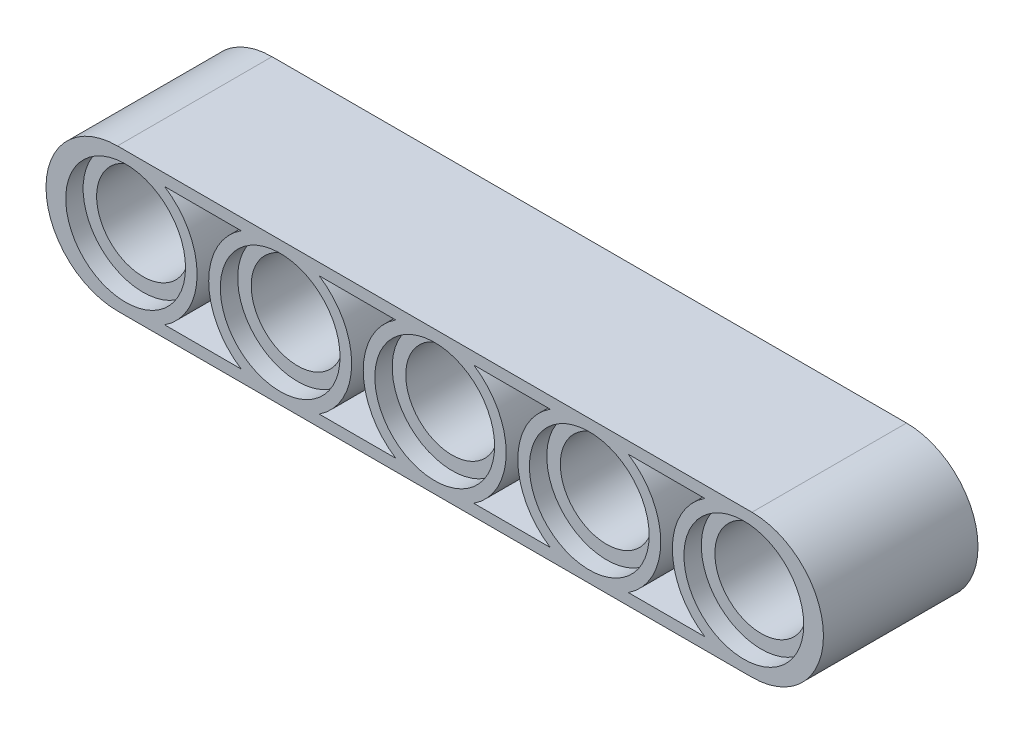
from build123d import *

# Parameters (mm, degrees)
OUTER_SHAPE_DEPTH  = 4
MIDDLE_WALL_DEPTH  = 0.1
HOLES_R            = 3.1
OUTER_HOLE_DEPTH   = 3.9
SKETCH3_R          = 3.1
SKETCH3_R_2        = 2.4
INNER_HOLE_DEPTH   = 3.1
SKETCH4_R          = 2.4
THROUGH_HOLE_DEPTH = 5


with BuildPart() as part:
    # Sketch1 → Outer Shape (new body)
    with BuildSketch(Plane.XY):
        with BuildLine():
            Line((-16.421445021, 3.7), (16.421445021, 3.7))
            ThreePointArc((16.421445021, 3.7), (20.121445021, 0), (16.421445021, -3.7))
            Line((16.421445021, -3.7), (-16.421445021, -3.7))
            ThreePointArc((-16.421445021, -3.7), (-20.121445021, 0), (-16.421445021, 3.7))
        make_face()
        with BuildLine():
            Line((-16, 3.1), (16, 3.1))
            ThreePointArc((16, 3.1), (19.1, 0), (16, -3.1))
            Line((16, -3.1), (-16, -3.1))
            ThreePointArc((-16, -3.1), (-19.1, 0), (-16, 3.1))
        make_face(mode=Mode.SUBTRACT)
    extrude(amount=OUTER_SHAPE_DEPTH)



with BuildPart() as body_2:
    # Sketch2 → Middle wall (new body)
    with BuildSketch(Plane.XY):
        with BuildLine():
            Line((-15.918927506, 3.189649288), (15.918927506, 3.189649288))
            ThreePointArc((15.918927506, 3.189649288), (19.108576794, 0), (15.918927506, -3.189649288))
            Line((15.918927506, -3.189649288), (-15.918927506, -3.189649288))
            ThreePointArc((-15.918927506, -3.189649288), (-19.108576794, 0), (-15.918927506, 3.189649288))
        make_face()
    extrude(amount=MIDDLE_WALL_DEPTH)


with BuildPart() as part_1:
    add(part.part)

    add(body_2.part)  # Outer Hole merges body 2
    # Holes → Outer Hole (add)
    with BuildSketch(Plane.XY.offset(0.1)):
        with BuildLine():
            Line((-6.12486336, 3.189649288), (-9.87513664, 3.189649288))
            ThreePointArc((-9.87513664, 3.189649288), (-11.7, 0), (-9.87513664, -3.189649288))
            Line((-9.87513664, -3.189649288), (-6.12486336, -3.189649288))
            ThreePointArc((-6.12486336, -3.189649288), (-4.788457881, -1.837388695), (-4.3, 0))
            ThreePointArc((-4.3, 0), (-4.788457881, 1.837388695), (-6.12486336, 3.189649288))
        make_face()
        with Locations((-8, 0)):
            Circle(HOLES_R, mode=Mode.SUBTRACT)
        with BuildLine():
            ThreePointArc((-14.12486336, -3.189649288), (-12.788457881, -1.837388695), (-12.3, 0))
            ThreePointArc((-12.3, 0), (-12.788457881, 1.837388695), (-14.12486336, 3.189649288))
            Line((-14.12486336, 3.189649288), (-15.918927506, 3.189649288))
            ThreePointArc((-15.918927506, 3.189649288), (-19.108576794, 0), (-15.918927506, -3.189649288))
            Line((-15.918927506, -3.189649288), (-14.12486336, -3.189649288))
        make_face()
        with Locations((-16, 0)):
            Circle(HOLES_R, mode=Mode.SUBTRACT)
        with BuildLine():
            Line((1.87513664, 3.189649288), (-1.87513664, 3.189649288))
            ThreePointArc((-1.87513664, 3.189649288), (-3.7, 0), (-1.87513664, -3.189649288))
            Line((-1.87513664, -3.189649288), (1.87513664, -3.189649288))
            ThreePointArc((1.87513664, -3.189649288), (3.211542119, -1.837388695), (3.7, 0))
            ThreePointArc((3.7, 0), (3.211542119, 1.837388695), (1.87513664, 3.189649288))
        make_face()
        Circle(HOLES_R, mode=Mode.SUBTRACT)
        with BuildLine():
            Line((9.87513664, 3.189649288), (6.12486336, 3.189649288))
            ThreePointArc((6.12486336, 3.189649288), (4.3, 0), (6.12486336, -3.189649288))
            Line((6.12486336, -3.189649288), (9.87513664, -3.189649288))
            ThreePointArc((9.87513664, -3.189649288), (11.211542119, -1.837388695), (11.7, 0))
            ThreePointArc((11.7, 0), (11.211542119, 1.837388695), (9.87513664, 3.189649288))
        make_face()
        with Locations((8, 0)):
            Circle(HOLES_R, mode=Mode.SUBTRACT)
        with BuildLine():
            Line((15.918927506, 3.189649288), (14.12486336, 3.189649288))
            ThreePointArc((14.12486336, 3.189649288), (12.3, 0), (14.12486336, -3.189649288))
            Line((14.12486336, -3.189649288), (15.918927506, -3.189649288))
            ThreePointArc((15.918927506, -3.189649288), (19.108576794, 0), (15.918927506, 3.189649288))
        make_face()
        with Locations((16, 0)):
            Circle(HOLES_R, mode=Mode.SUBTRACT)
    extrude(amount=OUTER_HOLE_DEPTH)

    # Sketch3 → Inner Hole (add)
    with BuildSketch(Plane.XY):
        with Locations((-16, 0)):
            Circle(SKETCH3_R)
        with Locations((-16, 0)):
            Circle(SKETCH3_R_2, mode=Mode.SUBTRACT)
        with Locations((-8, 0)):
            Circle(SKETCH3_R)
        with Locations((-8, 0)):
            Circle(SKETCH3_R_2, mode=Mode.SUBTRACT)
        Circle(SKETCH3_R)
        Circle(SKETCH3_R_2, mode=Mode.SUBTRACT)
        with Locations((8, 0)):
            Circle(SKETCH3_R)
        with Locations((8, 0)):
            Circle(SKETCH3_R_2, mode=Mode.SUBTRACT)
        with Locations((16, 0)):
            Circle(SKETCH3_R)
        with Locations((16, 0)):
            Circle(SKETCH3_R_2, mode=Mode.SUBTRACT)
    extrude(amount=INNER_HOLE_DEPTH)

    # Sketch4 → Through Hole (cut, through all)
    with BuildSketch(Plane.XY):
        with Locations((-16, 0)):
            Circle(SKETCH4_R)
        with Locations((-8, 0)):
            Circle(SKETCH4_R)
        Circle(SKETCH4_R)
        with Locations((8, 0)):
            Circle(SKETCH4_R)
        with Locations((16, 0)):
            Circle(SKETCH4_R)
    extrude(amount=THROUGH_HOLE_DEPTH, mode=Mode.SUBTRACT)

    # Mirror1: part across face


with BuildPart() as part_2:
    add(part_1.part)
    add(part_1.part.mirror(Plane(origin=(0, 0, 0), x_dir=(1, 0, 0), z_dir=(0, 0, -1))))


solid = part_2.part
